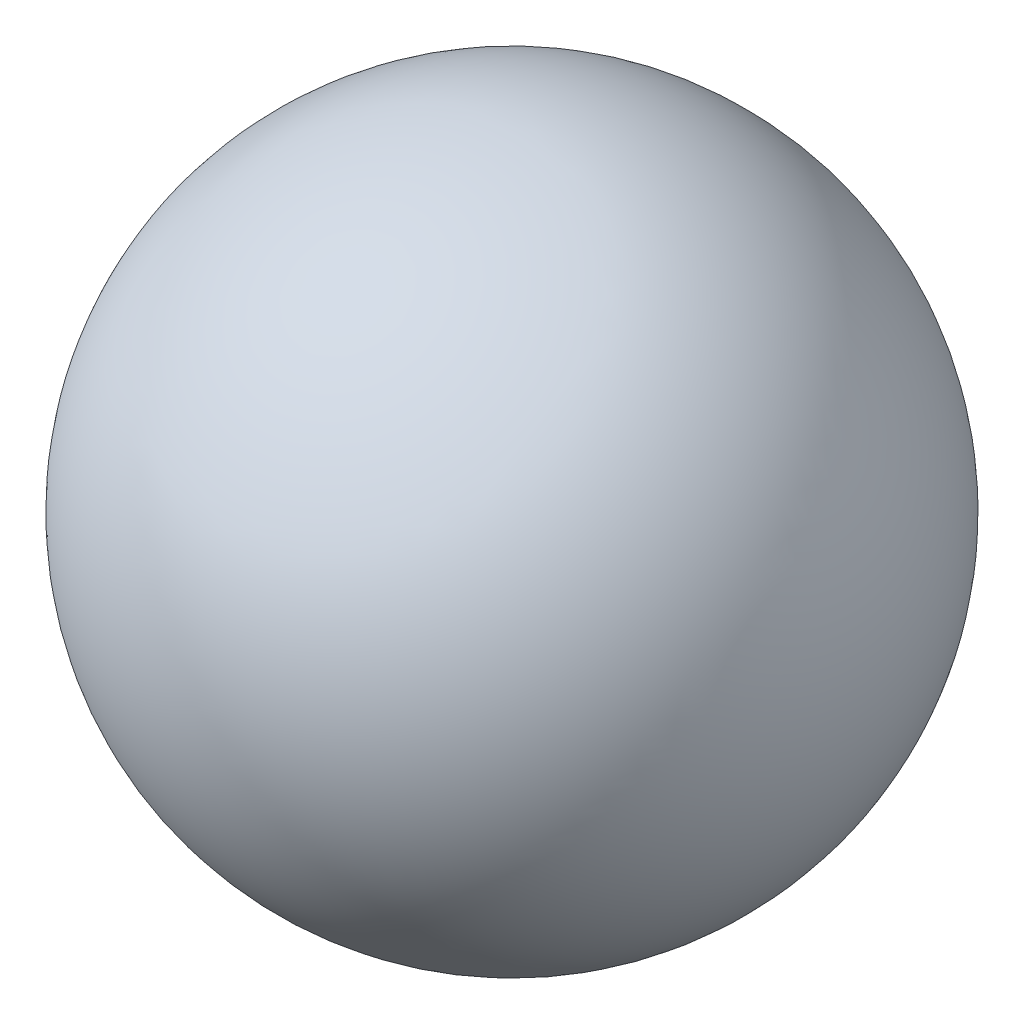
from build123d import *


with BuildPart() as part:
    # Sketch2 → Revolve1 (revolve)
    with BuildSketch(Plane.XY):
        with BuildLine():
            Line((-66.451215214, 0), (66.451215214, 0))
            ThreePointArc((66.451215214, 0), (0, 66.451215214), (-66.451215214, 0))
        make_face()
    revolve(axis=Axis((-66.451215214, 0, 0), (1, 0, 0)))


solid = part.part
